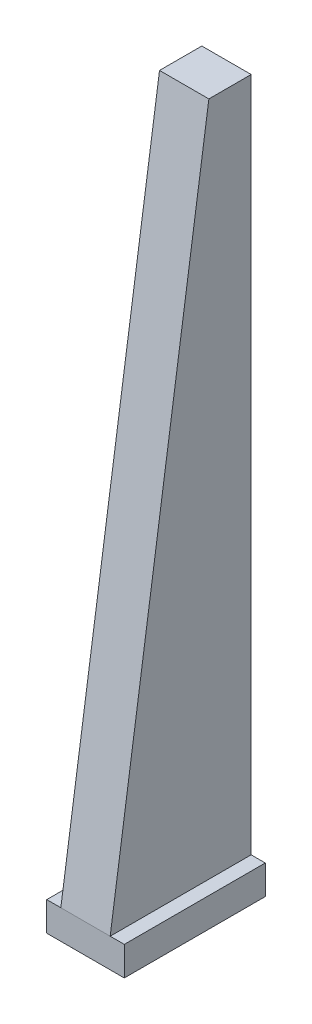
from build123d import *

# Parameters (mm, degrees)
BOSS_EXTRUDE1_DEPTH     = 254
CUT_EXTRUDE1_DEPTH      = 140.7
CUT_EXTRUDE1_DEPTH_BACK = 140.7


with BuildPart() as part:
    # Sketch1 → Boss-Extrude1 (new body, symmetric)
    with BuildSketch(Plane.XY):
        Polygon((88.9, 2540), (-88.9, 2540), (-88.9, 104.96042), (-139.7, 104.96042), (-139.7, 0), (139.7, 0), (139.7, 104.96042), (88.9, 104.96042), align=None)
    extrude(amount=BOSS_EXTRUDE1_DEPTH, both=True)

    # Sketch2 → Cut-Extrude1 (cut, two sides)
    with BuildSketch(Plane(origin=(0, 0, 0), x_dir=(0, 0, -1), z_dir=(1, 0, 0))) as cut_extrude1_sk:
        Polygon((-254, 104.96042), (101.6, 2540), (-254, 2540), align=None)
    extrude(amount=CUT_EXTRUDE1_DEPTH, mode=Mode.SUBTRACT)
    extrude(cut_extrude1_sk.sketch, amount=-CUT_EXTRUDE1_DEPTH_BACK, mode=Mode.SUBTRACT)


solid = part.part
